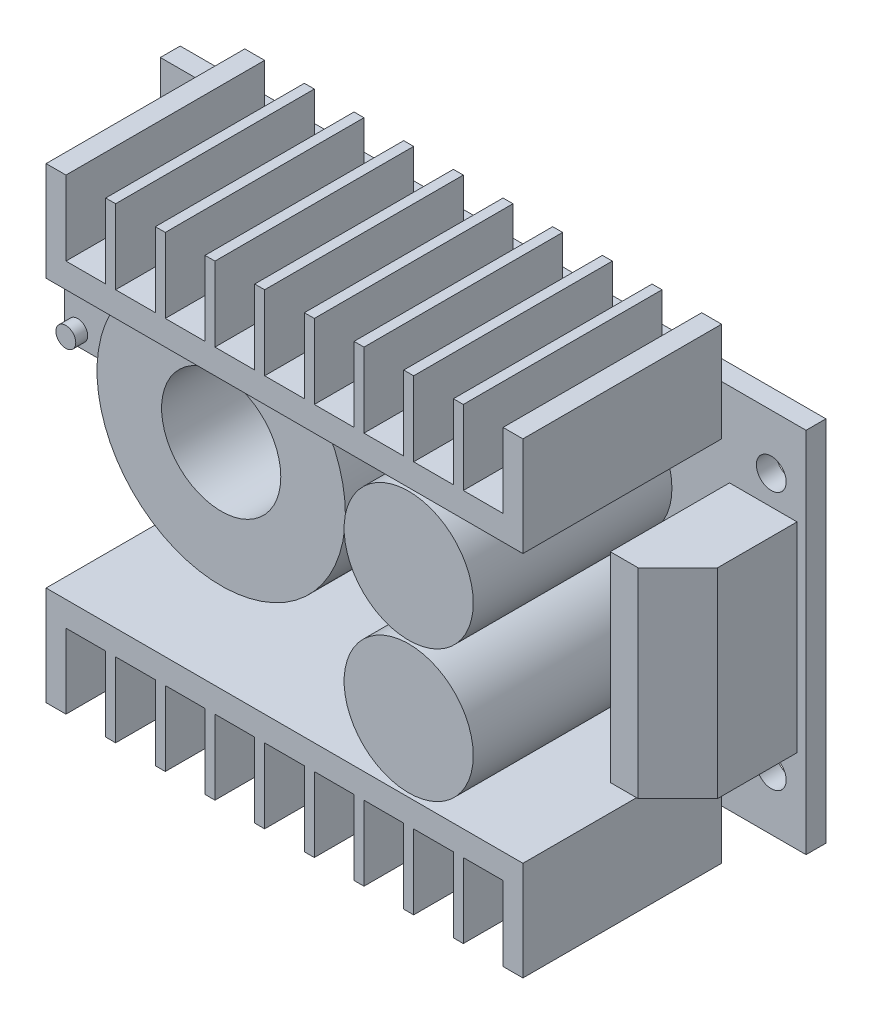
from build123d import *

# Parameters (mm, degrees)
SKETCH_1_W          = 65
SKETCH_1_H          = 37
EXTRUDE_1_DEPTH     = 2
EXTRUDE_2_DEPTH     = 20
SKETCH_3_R          = 6.5
EXTRUDE_3_DEPTH     = 20
SKETCH_4_R          = 12.5
SKETCH_4_R_2        = 6
EXTRUDE_4_DEPTH     = 12
SKETCH_5_W          = 5
SKETCH_5_H          = 10
EXTRUDE_5_DEPTH     = 10
SKETCH_6_R          = 1
EXTRUDE_6_DEPTH     = 1.2
SKETCH_7_W          = 6.798722996
SKETCH_7_H          = 20.12306807
EXTRUDE_7_DEPTH     = 12
CHAMFER_1_SIZE      = 4
SKETCH_8_R          = 1.5
CUT_EXTRUDE_1_DEPTH = 3


with BuildPart() as part:
    # Эскиз1 → Бобышка-Вытянуть1 (new body)
    with BuildSketch(Plane.XY):
        Rectangle(SKETCH_1_W, SKETCH_1_H)
    extrude(amount=EXTRUDE_1_DEPTH)

    # Эскиз2 → Бобышка-Вытянуть2 (add)
    with BuildSketch(Plane.XY.offset(2)):
        Polygon((-24, 23.5), (-24, 13.5), (24, 13.5), (24, 23.5), (22, 23.5), (22, 16), (18, 16), (18, 23.5), (17, 23.5), (17, 16), (13, 16), (13, 23.5), (12, 23.5), (12, 16), (8, 16), (8, 23.5), (7, 23.5), (7, 16), (3, 16), (3, 23.5), (2, 23.5), (2, 16), (-2, 16), (-2, 23.5), (-3, 23.5), (-3, 16), (-7, 16), (-7, 23.5), (-8, 23.5), (-8, 16), (-12, 16), (-12, 23.5), (-13, 23.5), (-13, 16), (-17, 16), (-17, 23.5), (-18, 23.5), (-18, 16), (-22, 16), (-22, 23.5), align=None)
        Polygon((22, -23.5), (24, -23.5), (24, -13.5), (-24, -13.5), (-24, -23.5), (-22, -23.5), (-22, -16), (-18, -16), (-18, -23.5), (-17, -23.5), (-17, -16), (-13, -16), (-13, -23.5), (-12, -23.5), (-12, -16), (-8, -16), (-8, -23.5), (-7, -23.5), (-7, -16), (-3, -16), (-3, -23.5), (-2, -23.5), (-2, -16), (2, -16), (2, -23.5), (3, -23.5), (3, -16), (7, -16), (7, -23.5), (8, -23.5), (8, -16), (12, -16), (12, -23.5), (13, -23.5), (13, -16), (17, -16), (17, -23.5), (18, -23.5), (18, -16), (22, -16), align=None)
    extrude(amount=EXTRUDE_2_DEPTH)

    # Эскиз3 → Бобышка-Вытянуть3 (add)
    with BuildSketch(Plane.XY.offset(2)):
        with Locations((12.5, 6.691570058)):
            Circle(SKETCH_3_R)
        with Locations((12.5, -6.612413993)):
            Circle(SKETCH_3_R)
    extrude(amount=EXTRUDE_3_DEPTH)

    # Эскиз4 → Бобышка-Вытянуть4 (add)
    with BuildSketch(Plane.XY.offset(2)):
        with Locations((-14.373526478, 0)):
            Circle(SKETCH_4_R)
        with Locations((-14.373526478, 0)):
            Circle(SKETCH_4_R_2, mode=Mode.SUBTRACT)
    extrude(amount=EXTRUDE_4_DEPTH)

    # Эскиз5 → Бобышка-Вытянуть5 (add)
    with BuildSketch(Plane.XY.offset(2)):
        with Locations((-29.649429854, 4.142703247)):
            Rectangle(SKETCH_5_W, SKETCH_5_H)
    extrude(amount=EXTRUDE_5_DEPTH)

    # Эскиз6 → Бобышка-Вытянуть6 (add)
    with BuildSketch(Plane.XY.offset(12)):
        with Locations((-30.813495229, 0.582032688)):
            Circle(SKETCH_6_R)
    extrude(amount=EXTRUDE_6_DEPTH)

    # Эскиз7 → Бобышка-Вытянуть7 (add)
    with BuildSketch(Plane.XY.offset(2)):
        with Locations((28.195350692, 0)):
            Rectangle(SKETCH_7_W, SKETCH_7_H)
    extrude(amount=EXTRUDE_7_DEPTH)

    # Фаска1
    chamfer_1_edges = [part.edges().sort_by_distance(p)[0] for p in [
        (31.59471219, 0, 14),
    ]]
    chamfer(chamfer_1_edges, length=CHAMFER_1_SIZE)

    # Эскиз8 → Вырез-Вытянуть1 (cut, through all)
    with BuildSketch(Plane.XY.offset(2)):
        with Locations((-29, 13)):
            Circle(SKETCH_8_R)
        with Locations((29, 13)):
            Circle(SKETCH_8_R)
        with Locations((29, -13)):
            Circle(SKETCH_8_R)
        with Locations((-29, -13)):
            Circle(SKETCH_8_R)
    extrude(amount=-CUT_EXTRUDE_1_DEPTH, mode=Mode.SUBTRACT)


solid = part.part
